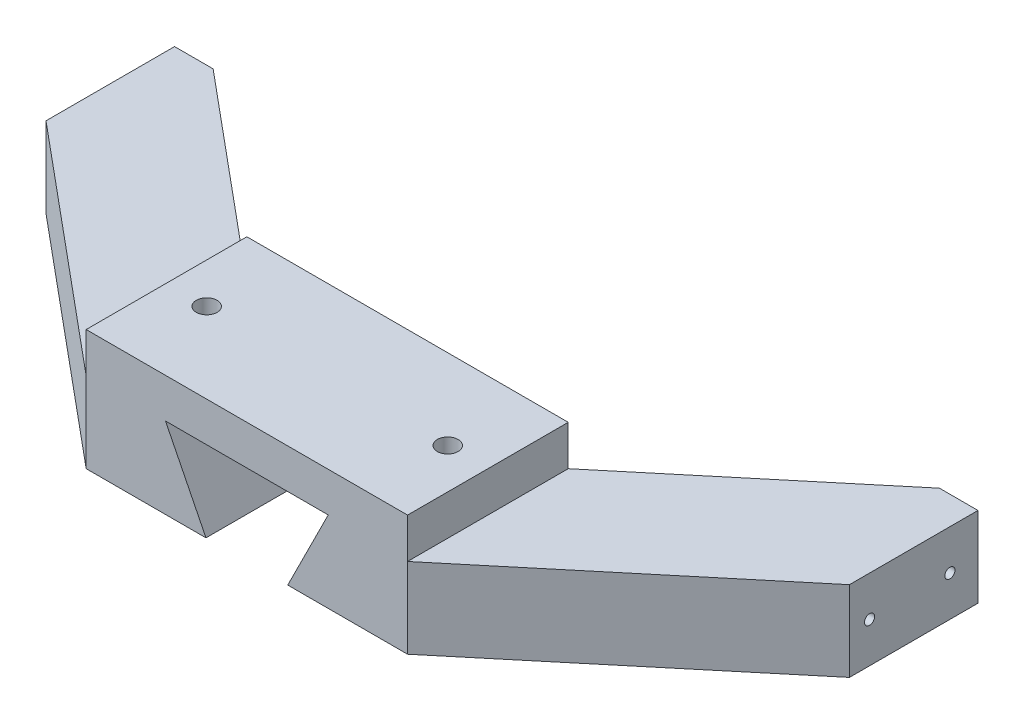
from build123d import *

# Parameters (mm, degrees)
SKETCH1_W                      = 50.8
SKETCH1_H                      = 19.05
BOSS_EXTRUDE1_DEPTH            = 25.4
CUT_EXTRUDE1_DEPTH             = 38.162422217
CUT_EXTRUDE1_DEPTH_BACK        = 38.1
M4X0_7_TAPPED_HOLE1_D          = 3.3
M4X0_7_TAPPED_HOLE1_DEPTH      = 10.1092
M4X0_7_TAPPED_HOLE1_TIP        = 0.991420021
BOSS_EXTRUDE4_DEPTH            = 12.7
M2X0_4_TAPPED_HOLE1_AT_2_COUNT = 2
M2X0_4_TAPPED_HOLE1_AT_2_PITCH = 12.7
CUT_EXTRUDE2_DEPTH             = 12.7


with BuildPart() as part:
    # Sketch1 → Boss-Extrude1 (new body)
    with BuildSketch(Plane.XY):
        Rectangle(SKETCH1_W, SKETCH1_H)
    extrude(amount=BOSS_EXTRUDE1_DEPTH)

    # Sketch2 → Cut-Extrude1 (cut, two sides)
    with BuildSketch(Plane(origin=(0, 0, 0), x_dir=(-1, 0, 0), z_dir=(0, 0, -1))) as cut_extrude1_sk:
        Polygon((-6.461803399, -9.525), (-6.35, -9.525), (-12.7, 3.175), (12.7, 3.175), (6.35, -9.525), (6.461803399, -9.525), (12.861803399, 3.275), (-12.861803399, 3.275), align=None)
        Polygon((-12.7, 3.175), (-6.35, -9.525), (6.35, -9.525), (12.7, 3.175), align=None)
    extrude(amount=CUT_EXTRUDE1_DEPTH, mode=Mode.SUBTRACT)
    extrude(cut_extrude1_sk.sketch, amount=-CUT_EXTRUDE1_DEPTH_BACK, mode=Mode.SUBTRACT)

    # M4x0.7 Tapped Hole1
    with Locations(Plane(origin=(0, 9.525, 0), x_dir=(1, 0, 0), z_dir=(0, 1, 0))):
        with Locations((-19.05, -12.7), (19.05, -12.7)):
            Hole(M4X0_7_TAPPED_HOLE1_D / 2, depth=M4X0_7_TAPPED_HOLE1_DEPTH)
            with Locations((0, 0, -(M4X0_7_TAPPED_HOLE1_DEPTH + M4X0_7_TAPPED_HOLE1_TIP / 2))):  # 118° drill point
                Cone(0, M4X0_7_TAPPED_HOLE1_D / 2, M4X0_7_TAPPED_HOLE1_TIP, mode=Mode.SUBTRACT)

    # Sketch8 → Boss-Extrude4 (add)
    with BuildSketch(Plane.XZ.offset(9.525)):
        Polygon((25.4, 25.4), (63.5, -6.35), (63.5, -31.75), (25.4, 0), align=None)
    boss_extrude4 = extrude(amount=-BOSS_EXTRUDE4_DEPTH)

    # Sketch19 → M2x0.4 Tapped Hole1 (revolve, cut)
    with BuildSketch(Plane(origin=(63.5, -3.175, -22.225), x_dir=(0, 0, -1), z_dir=(0, 1, 0))):
        Polygon((0, 0), (0, 6.830688495), (0.8, 6.35), (0.8, 0), align=None)
    m2x0_4_tapped_hole1 = revolve(axis=Axis((69.85, -3.175, -22.225), (-1, 0, 0)), mode=Mode.SUBTRACT)

    # M2x0.4 Tapped Hole1 at 2: M2x0.4 Tapped Hole1 ×2
    with Locations(*[(0, 0, i * M2X0_4_TAPPED_HOLE1_AT_2_PITCH) for i in range(1, M2X0_4_TAPPED_HOLE1_AT_2_COUNT)]):
        add(m2x0_4_tapped_hole1, mode=Mode.SUBTRACT)

    # Sketch20 → Cut-Extrude2 (cut)
    with BuildSketch(Plane(origin=(0, 3.175, 0), x_dir=(1, 0, 0), z_dir=(0, 1, 0))):
        Polygon((57.404, 26.67), (63.5, 26.67), (63.5, 31.75), align=None)
    cut_extrude2 = extrude(amount=-CUT_EXTRUDE2_DEPTH, mode=Mode.SUBTRACT)

    # Mirror1: Boss-Extrude4, M2x0.4 Tapped Hole1, Cut-Extrude2 across plane
    add(boss_extrude4.mirror(Plane(origin=(0, 0, 0), x_dir=(0, 0, 1), z_dir=(1, 0, 0))))
    add(m2x0_4_tapped_hole1.mirror(Plane(origin=(0, 0, 0), x_dir=(0, 0, 1), z_dir=(1, 0, 0))), mode=Mode.SUBTRACT)
    add(cut_extrude2.mirror(Plane(origin=(0, 0, 0), x_dir=(0, 0, 1), z_dir=(1, 0, 0))), mode=Mode.SUBTRACT)

    # Mirror1 copy 1 sketch → Mirror1 copy 1 (revolve, cut)
    with BuildSketch(Plane(origin=(-63.5, -3.175, -9.525), x_dir=(0, 0, -1), z_dir=(0, 1, 0))):
        Polygon((0, 0), (0, -6.830688495), (0.8, -6.35), (0.8, 0), align=None)
    revolve(axis=Axis((-69.85, -3.175, -9.525), (-1, 0, 0)), mode=Mode.SUBTRACT)


solid = part.part
